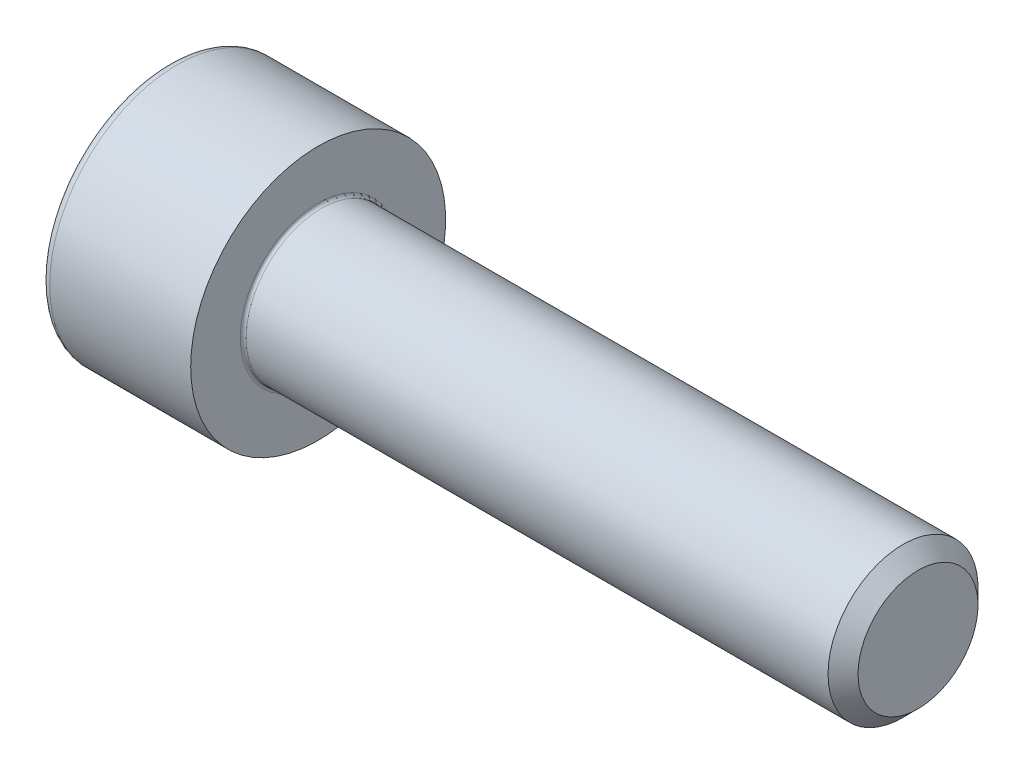
from build123d import *

# Parameters (mm, degrees)
FILLET1_R   = 0.1
FILLET2_R   = 0.3
HEX_2_DEPTH = 1.3


with BuildPart() as part:
    # BodySke → Base-Revolve (revolve)
    with BuildSketch(Plane.XY):
        Polygon((0, 0), (0, 4.25), (5, 4.25), (5, 2.5), (24.5, 2.5), (25, 2), (25, 0), align=None)
    revolve(axis=Axis((-31.75, 0, 0), (1, 0, 0)))

    # Fillet1
    fillet1_edges = [part.edges().sort_by_distance(p)[0] for p in [
        (5, -2.5, 0),
    ]]
    fillet(fillet1_edges, radius=FILLET1_R)

    # Fillet2
    fillet2_edges = [part.edges().sort_by_distance(p)[0] for p in [
        (0, -4.25, 0),
    ]]
    fillet(fillet2_edges, radius=FILLET2_R)

    # Sketch2 → Hex-PreBroach (revolve, cut)
    with BuildSketch(Plane.XY):
        Polygon((0, 2), (1.3, 2), (2.454700538, 0), (0, 0), align=None)
    revolve(axis=Axis((0, 0, 0), (1, 0, 0)), mode=Mode.SUBTRACT)

    # Sketch3 → Hex 2 (cut)
    with BuildSketch(Plane(origin=(0, 0, 0), x_dir=(0, 0.5, 0.866025404), z_dir=(-1, 0, 0))):
        Polygon((1.154700538, 2), (-1.154700538, 2), (-2.309401077, 0), (-1.154700538, -2), (1.154700538, -2), (2.309401077, 0), align=None)
    extrude(amount=-HEX_2_DEPTH, mode=Mode.SUBTRACT)


solid = part.part
